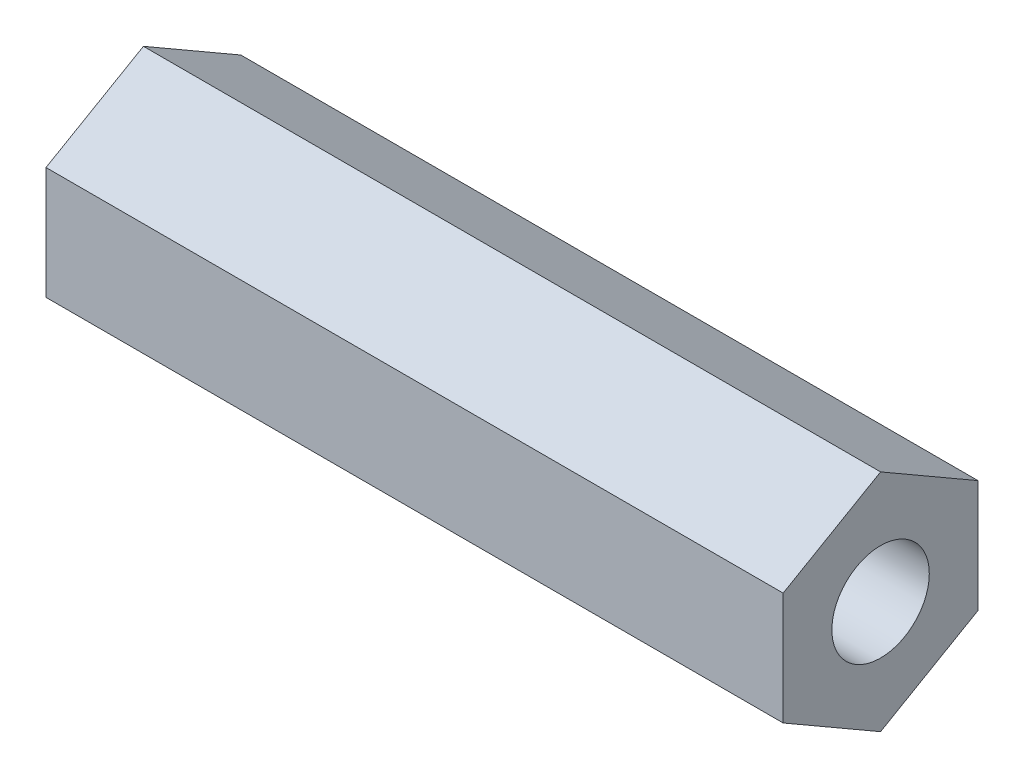
from build123d import *

# Parameters (mm, degrees)
SKETCH1_R           = 1.5
BOSS_EXTRUDE1_DEPTH = 22.7


with BuildPart() as part:
    # Sketch1 → Boss-Extrude1 (new body)
    with BuildSketch(Plane(origin=(0, 0, 0), x_dir=(0, 0, -1), z_dir=(1, 0, 0))):
        Polygon((-42.728336364, 8.277130653), (-45.728336364, 6.545079846), (-45.728336364, 3.08097823), (-42.728336364, 1.348927423), (-39.728336364, 3.08097823), (-39.728336364, 6.545079846), align=None)
        with Locations((-42.728336364, 4.813029038)):
            Circle(SKETCH1_R, mode=Mode.SUBTRACT)
    extrude(amount=BOSS_EXTRUDE1_DEPTH)


solid = part.part
